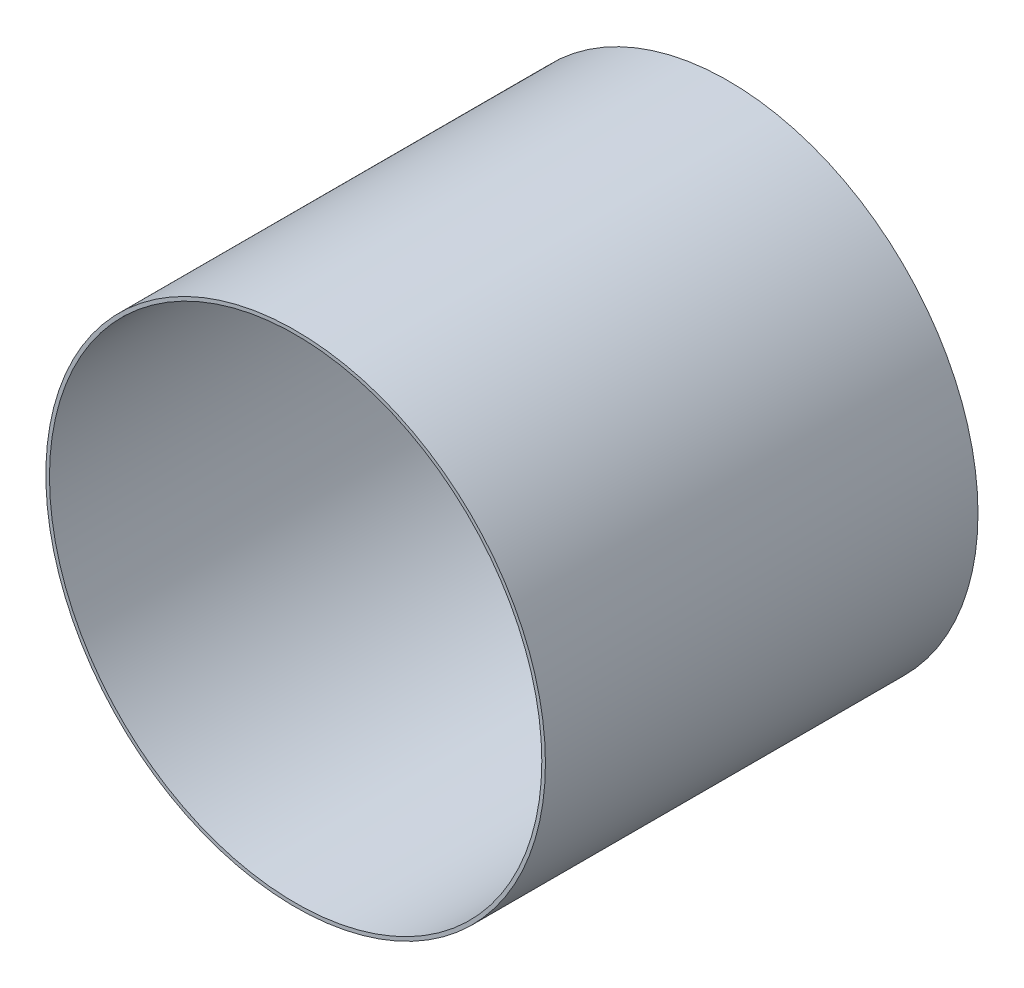
from build123d import *

# Parameters (mm, degrees)
SCHIZZO1_R                   = 448.3
SCHIZZO1_R_2                 = 441.8
ESTRUSIONE_ESTRUSIONE1_DEPTH = 776.3


with BuildPart() as part:
    # Schizzo1 → Estrusione-Estrusione1 (new body)
    with BuildSketch(Plane.XY):
        Circle(SCHIZZO1_R)
        Circle(SCHIZZO1_R_2, mode=Mode.SUBTRACT)
    extrude(amount=ESTRUSIONE_ESTRUSIONE1_DEPTH)


solid = part.part
